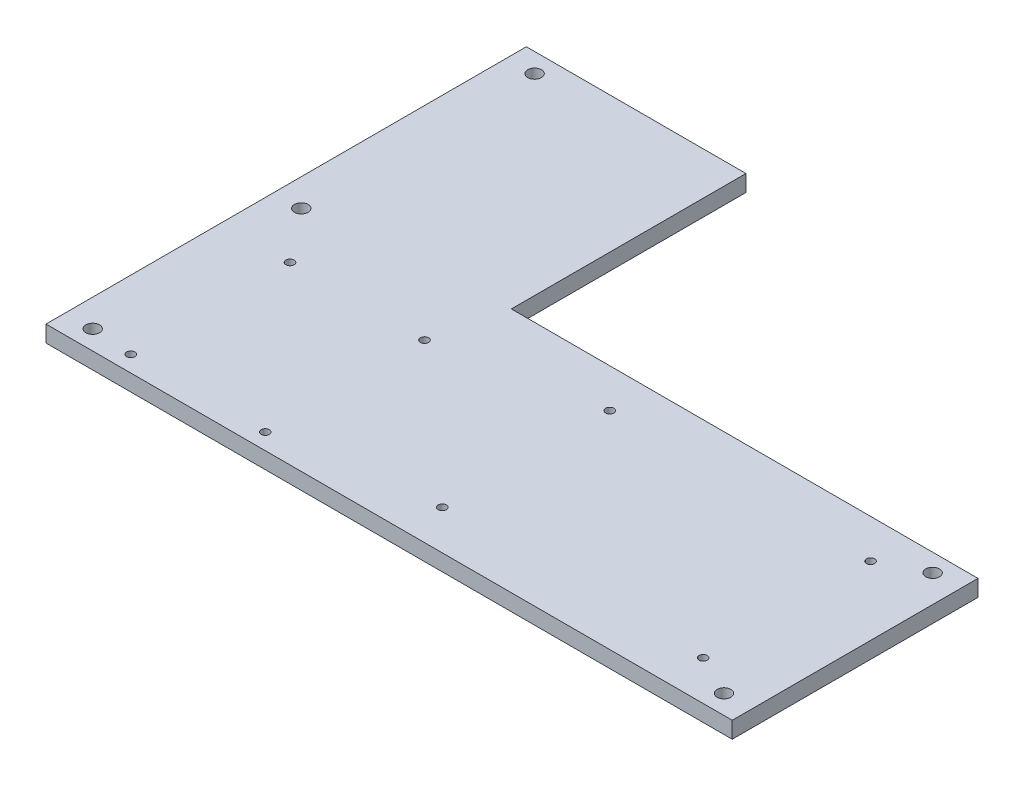
from build123d import *

# Parameters (mm, degrees)
BOSS_EXTRUDE1_DEPTH = 6
SKETCH1_3_R         = 1.5
SKETCH1_3_R_2       = 2.5
CUT_EXTRUDE1_DEPTH  = 6
SKETCH1_4_R         = 1.5
SKETCH1_4_R_2       = 2.5
CUT_EXTRUDE3_DEPTH  = 6


with BuildPart() as part:
    # Sketch1 → Boss-Extrude1 (new body)
    with BuildSketch(Plane(origin=(0, 0, 0), x_dir=(1, 0, 0), z_dir=(0, 1, 0))):
        Polygon((-125.323936458, 45.11669536), (-125.323936458, 130.11669536), (-45.323936458, 130.11669536), (-45.323936458, 44.651121259), (124.675630024, 44.651121259), (124.675630024, -44.88330464), (-125.323936458, -44.88330464), align=None)
    extrude(amount=BOSS_EXTRUDE1_DEPTH)

    # Sketch1_3 → Cut-Extrude1 (cut)
    with BuildSketch(Plane(origin=(0, 0, 0), x_dir=(1, 0, 0), z_dir=(0, 1, 0))):
        with Locations((-100.323936458, 19)):
            Circle(SKETCH1_3_R)
        with Locations((-51.323936458, 19)):
            Circle(SKETCH1_3_R)
        with Locations((-51.323936458, -39)):
            Circle(SKETCH1_3_R)
        with Locations((-100.323936458, -39)):
            Circle(SKETCH1_3_R)
        with Locations((-115.323936458, 123.11669536)):
            Circle(SKETCH1_3_R_2)
    extrude(amount=CUT_EXTRUDE1_DEPTH, mode=Mode.SUBTRACT)

    # Sketch1_4 → Cut-Extrude3 (cut)
    with BuildSketch(Plane(origin=(0, 0, 0), x_dir=(1, 0, 0), z_dir=(0, 1, 0))):
        with Locations((4.675630024, 30.5)):
            Circle(SKETCH1_4_R)
        with Locations((99.675630024, 30.5)):
            Circle(SKETCH1_4_R)
        with Locations((99.675630024, -30.5)):
            Circle(SKETCH1_4_R)
        with Locations((4.675630024, -30.5)):
            Circle(SKETCH1_4_R)
        with Locations((-115.323936458, 38.11669536)):
            Circle(SKETCH1_4_R_2)
        with Locations((-115.323936458, -37.88330464)):
            Circle(SKETCH1_4_R_2)
        with Locations((114.675630024, -37.88330464)):
            Circle(SKETCH1_4_R_2)
        with Locations((114.675630024, 38.11669536)):
            Circle(SKETCH1_4_R_2)
    extrude(amount=CUT_EXTRUDE3_DEPTH, mode=Mode.SUBTRACT)


solid = part.part
